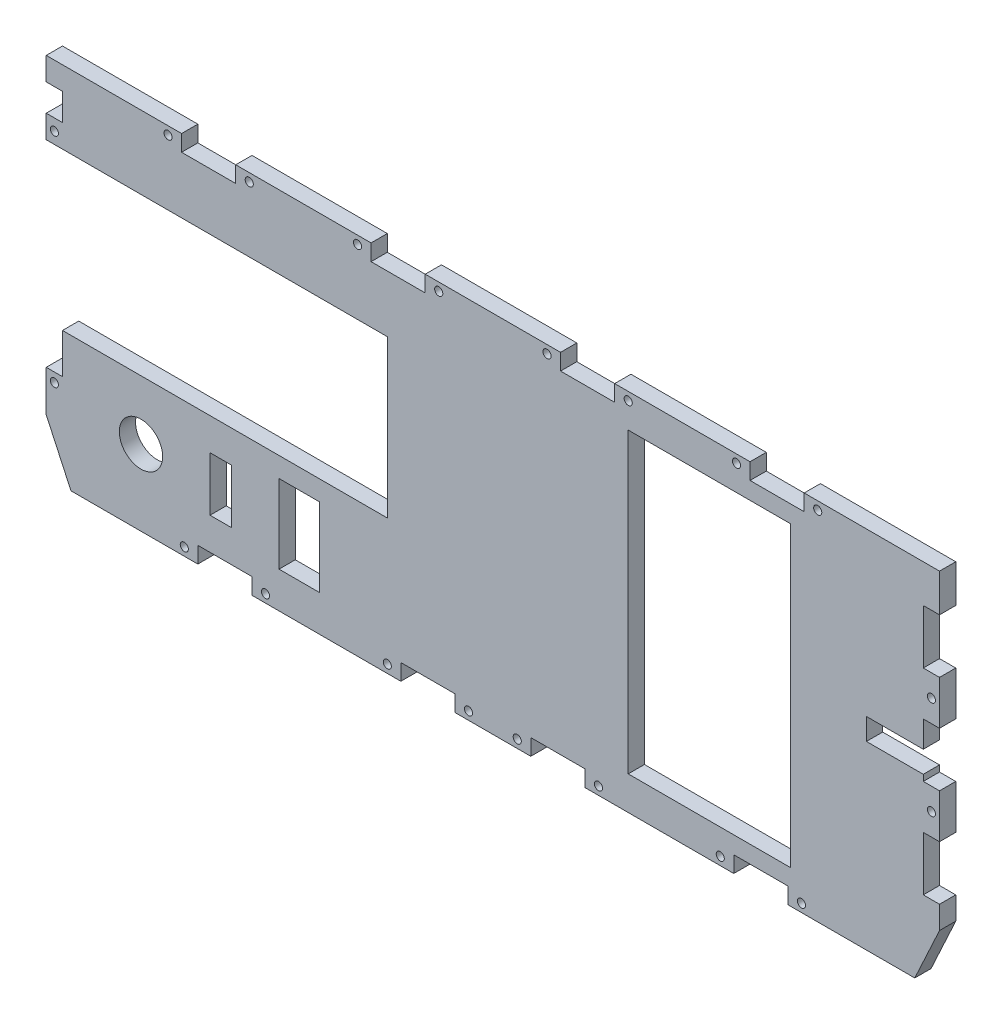
from build123d import *

# Parameters (mm, degrees)
BOSS_EXTRU_1_DEPTH      = 6
ESQUISSE3_R             = 8
ESQUISSE3_W             = 6
ESQUISSE3_H             = 10
ESQUISSE3_W_2           = 20
ESQUISSE3_H_2           = 6
ESQUISSE3_W_3           = 60
ESQUISSE3_H_3           = 110
ESQUISSE3_H_4           = 20
ESQUISSE3_W_4           = 8
ESQUISSE3_W_5           = 15
ESQUISSE3_H_5           = 29
ENL_V_MAT_EXTRU_2_DEPTH = 6
ESQUISSE4_R             = 1.5
ENL_V_MAT_EXTRU_3_DEPTH = 6
ESQUISSE5_W             = 456.045253014
ESQUISSE5_H             = 136.228984631
ENL_V_MAT_EXTRU_4_DEPTH = 6
ESQUISSE6_W             = 21
ESQUISSE6_H             = 8
ENL_V_MAT_EXTRU_5_DEPTH = 10


with BuildPart() as part:
    # Esquisse1 → Boss.-Extru.1 (new body)
    with BuildSketch(Plane.XY):
        Polygon((-165, 96.73), (165, 96.73), (165, -18.27), (123, -109.022410436), (-123, -109.022410436), (-165, -18.27), align=None)
    extrude(amount=BOSS_EXTRU_1_DEPTH)

    # Esquisse3 → Enlèv. mat.-Extru.2 (cut)
    with BuildSketch(Plane(origin=(0, 0, 0), x_dir=(-1, 0, 0), z_dir=(0, 0, -1))):
        with Locations((130, -10.145)):
            Circle(ESQUISSE3_R)
        Polygon((165, -3.06), (159, -3.06), (159, 11.73), (39, 11.73), (39, 69.73), (165, 69.73), align=None)
        with Locations((162, 83.23258956)):
            Rectangle(ESQUISSE3_W, ESQUISSE3_H)
        with Locations((-24, -35.02)):
            Rectangle(ESQUISSE3_W_2, ESQUISSE3_H_2)
        with Locations((99, -35.02)):
            Rectangle(ESQUISSE3_W_2, ESQUISSE3_H_2)
        with Locations((-80, 29.355)):
            Rectangle(ESQUISSE3_W_3, ESQUISSE3_H_3)
        with Locations((-162, 72.73)):
            Rectangle(ESQUISSE3_W, ESQUISSE3_H_4)
        with Locations((24, -35.02)):
            Rectangle(ESQUISSE3_W_2, ESQUISSE3_H_2)
        with Locations((-162, 36.44)):
            Rectangle(ESQUISSE3_W, ESQUISSE3_H_4)
        with Locations((-162, 0.15)):
            Rectangle(ESQUISSE3_W, ESQUISSE3_H_4)
        with Locations((105, 93.73)):
            Rectangle(ESQUISSE3_W_2, ESQUISSE3_H_2)
        with Locations((-35, 93.73)):
            Rectangle(ESQUISSE3_W_2, ESQUISSE3_H_2)
        with Locations((35, 93.73)):
            Rectangle(ESQUISSE3_W_2, ESQUISSE3_H_2)
        with Locations((-105, 93.73)):
            Rectangle(ESQUISSE3_W_2, ESQUISSE3_H_2)
        with Locations((100.5, -10.145)):
            Rectangle(ESQUISSE3_W_4, ESQUISSE3_H_4)
        with Locations((-99, -35.02)):
            Rectangle(ESQUISSE3_W_2, ESQUISSE3_H_2)
        with Locations((71.5, -10.145)):
            Rectangle(ESQUISSE3_W_5, ESQUISSE3_H_5)
    extrude(amount=-ENL_V_MAT_EXTRU_2_DEPTH, mode=Mode.SUBTRACT)

    # Esquisse4 → Enlèv. mat.-Extru.3 (cut)
    with BuildSketch(Plane(origin=(0, 0, 0), x_dir=(-1, 0, 0), z_dir=(0, 0, -1))):
        with Locations((114, -35.02)):
            Circle(ESQUISSE4_R)
        with Locations((162, 73.98258956)):
            Circle(ESQUISSE4_R)
        with Locations((84, -35.02)):
            Circle(ESQUISSE4_R)
        with Locations((39, -35.02)):
            Circle(ESQUISSE4_R)
        with Locations((162, -6.46)):
            Circle(ESQUISSE4_R)
        with Locations((9, -35.02)):
            Circle(ESQUISSE4_R)
        with Locations((-9, -35.02)):
            Circle(ESQUISSE4_R)
        with Locations((-39, -35.02)):
            Circle(ESQUISSE4_R)
        with Locations((-84, -35.02)):
            Circle(ESQUISSE4_R)
        with Locations((120, 93.73)):
            Circle(ESQUISSE4_R)
        with Locations((-114, -35.02)):
            Circle(ESQUISSE4_R)
        with Locations((90, 93.73)):
            Circle(ESQUISSE4_R)
        with Locations((50, 93.73)):
            Circle(ESQUISSE4_R)
        with Locations((20, 93.73)):
            Circle(ESQUISSE4_R)
        with Locations((-162, 18.29)):
            Circle(ESQUISSE4_R)
        with Locations((-162, 54.585)):
            Circle(ESQUISSE4_R)
        with Locations((-20, 93.73)):
            Circle(ESQUISSE4_R)
        with Locations((-50, 93.73)):
            Circle(ESQUISSE4_R)
        with Locations((-90, 93.73)):
            Circle(ESQUISSE4_R)
        with Locations((-120, 93.73)):
            Circle(ESQUISSE4_R)
    extrude(amount=-ENL_V_MAT_EXTRU_3_DEPTH, mode=Mode.SUBTRACT)

    # Esquisse5 → Enlèv. mat.-Extru.4 (cut)
    with BuildSketch(Plane(origin=(0, 0, 0), x_dir=(-1, 0, 0), z_dir=(0, 0, -1))):
        with Locations((-18.307092018, -106.134492316)):
            Rectangle(ESQUISSE5_W, ESQUISSE5_H)
    extrude(amount=-ENL_V_MAT_EXTRU_4_DEPTH, mode=Mode.SUBTRACT)

    # Esquisse6 → Enlèv. mat.-Extru.5 (cut)
    with BuildSketch(Plane(origin=(0, 0, 0), x_dir=(-1, 0, 0), z_dir=(0, 0, -1))):
        with Locations((-148.5, 32.73)):
            Rectangle(ESQUISSE6_W, ESQUISSE6_H)
    extrude(amount=-ENL_V_MAT_EXTRU_5_DEPTH, mode=Mode.SUBTRACT)


solid = part.part
